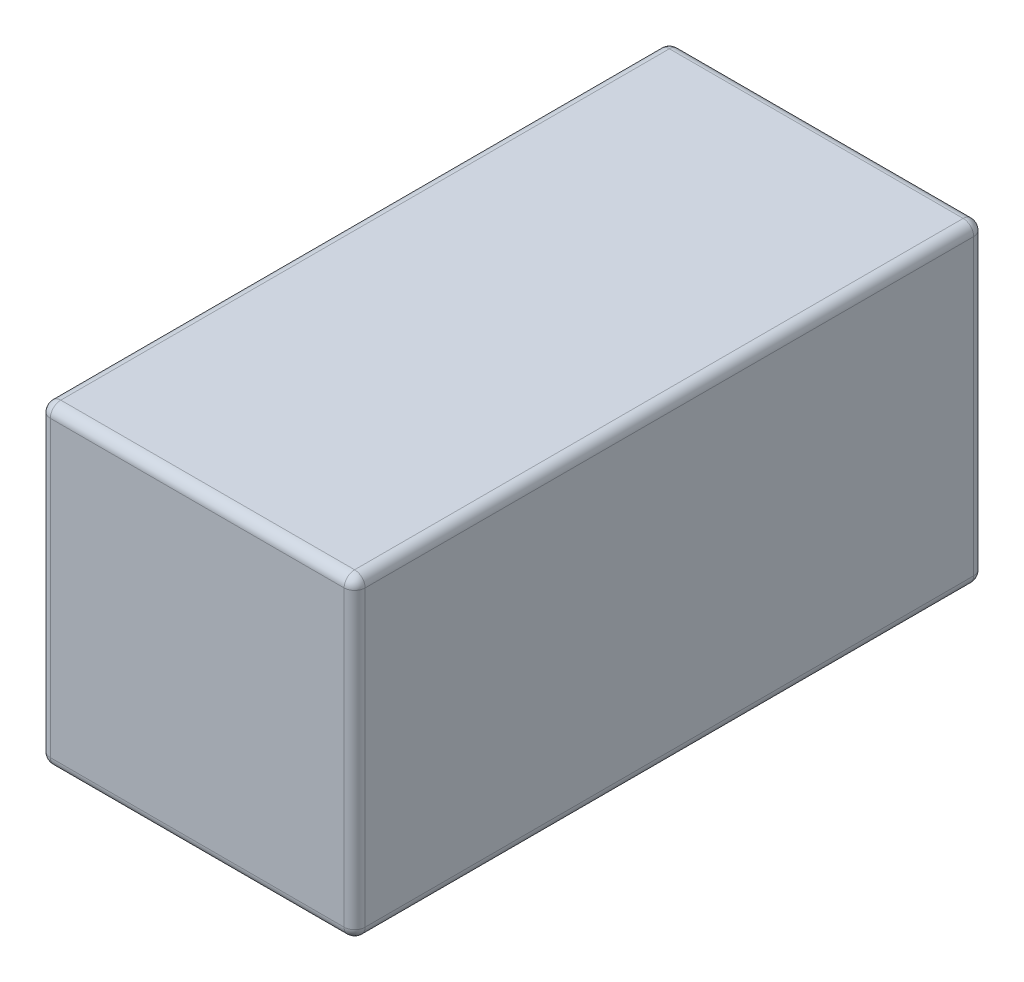
from build123d import *

# Parameters (mm, degrees)
SKETCH3_W                = 6
SKETCH3_H                = 6
BOSS_EXTRUDE1_DEPTH      = 6
BOSS_EXTRUDE1_DEPTH_BACK = 6
FILLET2_R                = 0.2


with BuildPart() as part:
    # Sketch3 → Boss-Extrude1 (new body, two sides)
    with BuildSketch(Plane.XY) as boss_extrude1_sk:
        Rectangle(SKETCH3_W, SKETCH3_H)
    extrude(amount=BOSS_EXTRUDE1_DEPTH)
    extrude(boss_extrude1_sk.sketch, amount=-BOSS_EXTRUDE1_DEPTH_BACK)

    # Fillet2
    fillet2_edges = [part.edges().sort_by_distance(p)[0] for p in [
        (0, 3, 6),
        (0, -3, -6),
        (-3, 0, -6),
        (0, 3, -6),
        (3, 0, -6),
        (-3, 0, 6),
        (0, -3, 6),
        (3, 0, 6),
        (-3, -3, 0),
        (-3, 3, 0),
        (3, 3, 0),
        (3, -3, 0),
    ]]
    fillet(fillet2_edges, radius=FILLET2_R)


solid = part.part
